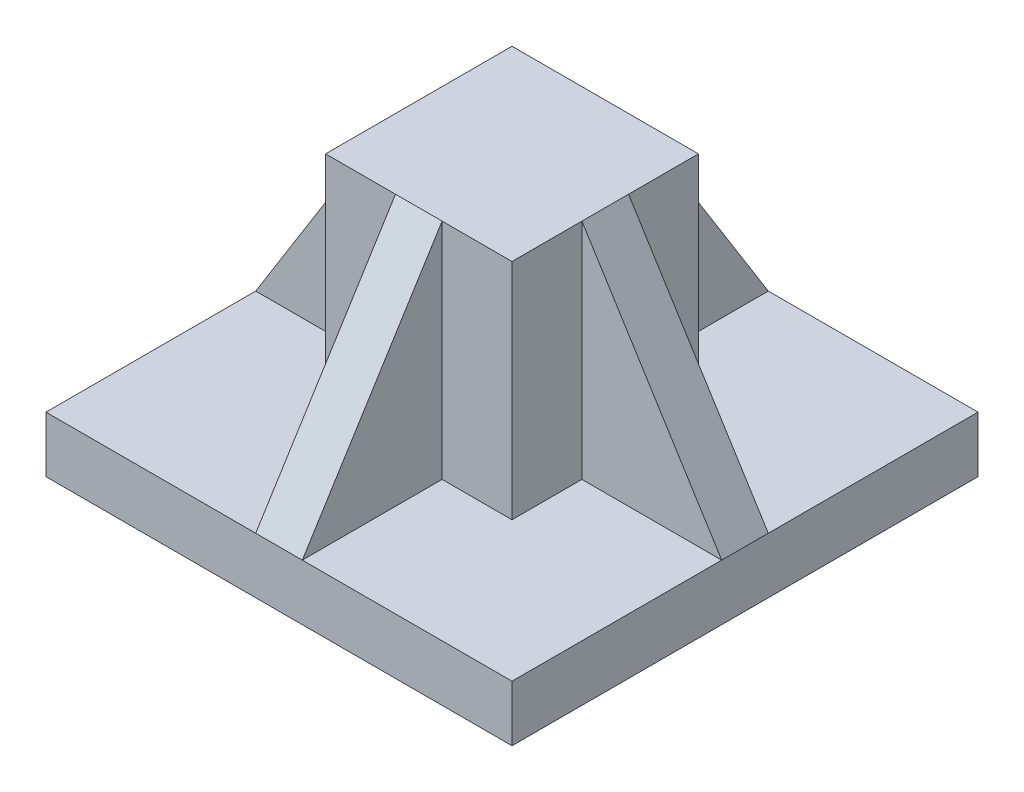
from build123d import *

# Parameters (mm, degrees)
CROQUIS1_W                   = 100
CROQUIS1_H                   = 100
SALIENTE_EXTRUIR1_DEPTH      = 12
CROQUIS2_W                   = 40
CROQUIS2_H                   = 40
SALIENTE_EXTRUIR2_DEPTH      = 60
SALIENTE_EXTRUIR3_DEPTH      = 5
SALIENTE_EXTRUIR3_DEPTH_BACK = 5
SALIENTE_EXTRUIR4_DEPTH      = 5
SALIENTE_EXTRUIR4_DEPTH_BACK = 5


with BuildPart() as part:
    # Croquis1 → Saliente-Extruir1 (new body)
    with BuildSketch(Plane(origin=(0, 0, 0), x_dir=(1, 0, 0), z_dir=(0, 1, 0))):
        Rectangle(CROQUIS1_W, CROQUIS1_H)
    extrude(amount=SALIENTE_EXTRUIR1_DEPTH)

    # Croquis2 → Saliente-Extruir2 (add)
    with BuildSketch(Plane(origin=(0, 0, 0), x_dir=(1, 0, 0), z_dir=(0, 1, 0))):
        Rectangle(CROQUIS2_W, CROQUIS2_H)
    extrude(amount=SALIENTE_EXTRUIR2_DEPTH)

    # Croquis3 → Saliente-Extruir3 (add, two sides)
    with BuildSketch(Plane.XY) as saliente_extruir3_sk:
        Polygon((20, 60), (50, 12), (20, 12), align=None)
        Polygon((-20, 60), (-50, 12), (-20, 12), align=None)
    extrude(amount=SALIENTE_EXTRUIR3_DEPTH)
    extrude(saliente_extruir3_sk.sketch, amount=-SALIENTE_EXTRUIR3_DEPTH_BACK)

    # Croquis4 → Saliente-Extruir4 (add, two sides)
    with BuildSketch(Plane(origin=(0, 0, 0), x_dir=(0, 0, -1), z_dir=(1, 0, 0))) as saliente_extruir4_sk:
        Polygon((-50, 12), (-20, 60), (-20, 12), align=None)
        Polygon((20, 60), (50, 12), (20, 12), align=None)
    extrude(amount=SALIENTE_EXTRUIR4_DEPTH)
    extrude(saliente_extruir4_sk.sketch, amount=-SALIENTE_EXTRUIR4_DEPTH_BACK)


solid = part.part
